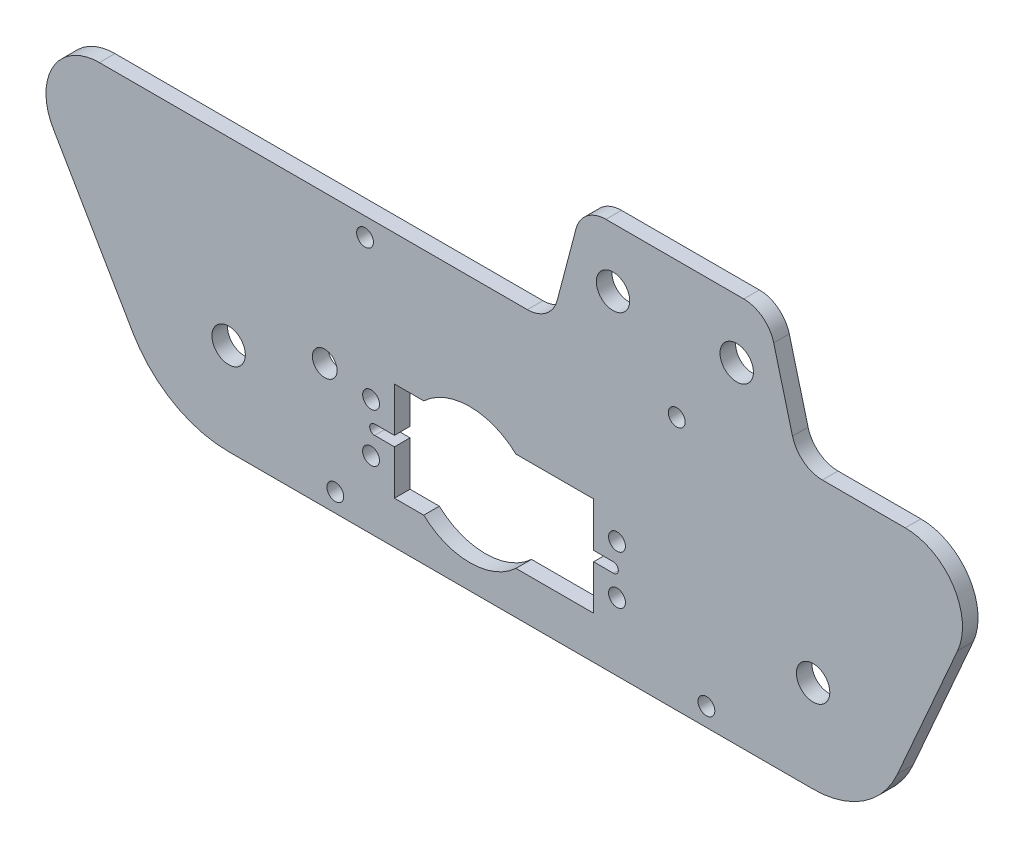
from build123d import *

# Parameters (mm, degrees)
SKETCH1_R           = 3.429
SKETCH1_R_2         = 2.54
BOSS_EXTRUDE1_DEPTH = 3.2004
SKETCH2_R           = 1.7272
CUT_EXTRUDE1_DEPTH  = 3.2004
SKETCH5_R           = 1.7272
SKETCH5_W           = 40.894
SKETCH5_H           = 20.32
CUT_EXTRUDE3_DEPTH  = 4.2004
CUT_EXTRUDE4_DEPTH  = 3.2004
SKETCH9_R           = 13.885201093
CUT_EXTRUDE7_DEPTH  = 3.2004
SKETCH10_R          = 3.429
BOSS_EXTRUDE2_DEPTH = 3.2004
FILLET1_R           = 6.35


with BuildPart() as part:
    # Sketch1 → Boss-Extrude1 (new body)
    with BuildSketch(Plane.XY):
        with BuildLine():
            Line((0, 0), (120.015, 0))
            ThreePointArc((120.015, 0), (130.351788397, 3.075697789), (137.325636158, 11.302152593))
            Line((137.325636158, 11.302152593), (149.69326877, 39.451329485))
            ThreePointArc((149.69326877, 39.451329485), (148.774539583, 50.600046625), (138.937102863, 55.925719911))
            Line((138.937102863, 55.925719911), (-26.54325766, 55.925719911))
            ThreePointArc((-26.54325766, 55.925719911), (-36.046025914, 50.429200208), (-36.019801229, 39.451329485))
            Line((-36.019801229, 39.451329485), (-19.648099871, 11.302152593))
            ThreePointArc((-19.648099871, 11.302152593), (-11.333429333, 3.027112684), (0, 0))
        make_face()
        with Locations((120.015, 18.90776)):
            Circle(SKETCH1_R, mode=Mode.SUBTRACT)
        with Locations((0, 18.90776)):
            Circle(SKETCH1_R, mode=Mode.SUBTRACT)
        with Locations((19.734727626, 25.566426992)):
            Circle(SKETCH1_R_2, mode=Mode.SUBTRACT)
    extrude(amount=BOSS_EXTRUDE1_DEPTH)

    # Sketch2 → Cut-Extrude1 (cut)
    with BuildSketch(Plane(origin=(0, 0, 0), x_dir=(-1, 0, 0), z_dir=(0, 0, -1))):
        with Locations((-92.0115, 52.115719911)):
            Circle(SKETCH2_R)
        with Locations((-28.0035, 52.115719911)):
            Circle(SKETCH2_R)
        with Locations((-98.1075, 3.81)):
            Circle(SKETCH2_R)
        with Locations((-21.9075, 3.81)):
            Circle(SKETCH2_R)
    extrude(amount=-CUT_EXTRUDE1_DEPTH, mode=Mode.SUBTRACT)

    # Sketch5 → Cut-Extrude3 (cut, through all)
    with BuildSketch(Plane(origin=(0, 0, 0), x_dir=(-1, 0, 0), z_dir=(0, 0, -1))):
        with Locations((-79.746999972, 23.90776)):
            Circle(SKETCH5_R)
        with Locations((-29.246999972, 13.90776)):
            Circle(SKETCH5_R)
        with Locations((-29.246999972, 23.90776)):
            Circle(SKETCH5_R)
        with Locations((-79.746999972, 13.90776)):
            Circle(SKETCH5_R)
        with Locations((-54.496999972, 18.90776)):
            Rectangle(SKETCH5_W, SKETCH5_H)
    extrude(amount=-CUT_EXTRUDE3_DEPTH, mode=Mode.SUBTRACT)

    # Sketch6 → Cut-Extrude4 (cut)
    with BuildSketch(Plane.XY.offset(3.2004)):
        with BuildLine():
            Line((29.985999972, 19.92376), (34.049999972, 19.92376))
            Line((34.049999972, 19.92376), (34.049999972, 17.89176))
            Line((34.049999972, 17.89176), (29.985999972, 17.89176))
            ThreePointArc((29.985999972, 17.89176), (28.969999972, 18.90776), (29.985999972, 19.92376))
        make_face()
        with BuildLine():
            Line((74.943999972, 19.92376), (79.007999972, 19.92376))
            ThreePointArc((79.007999972, 19.92376), (80.023999972, 18.90776), (79.007999972, 17.89176))
            Line((79.007999972, 17.89176), (74.943999972, 17.89176))
            Line((74.943999972, 17.89176), (74.943999972, 19.92376))
        make_face()
    extrude(amount=-CUT_EXTRUDE4_DEPTH, mode=Mode.SUBTRACT)

    # Sketch9 → Cut-Extrude7 (cut)
    with BuildSketch(Plane(origin=(0, 0, 0), x_dir=(-1, 0, 0), z_dir=(0, 0, -1))):
        with Locations((-49.53, 18.90776)):
            Circle(SKETCH9_R)
    extrude(amount=-CUT_EXTRUDE7_DEPTH, mode=Mode.SUBTRACT)

    # Sketch10 → Boss-Extrude2 (add)
    with BuildSketch(Plane.XY.offset(3.2004)):
        Polygon((72.5805, 80.055719911), (110.6805, 80.055719911), (117.0305, 55.925719911), (66.2305, 55.925719911), align=None)
        with Locations((78.9305, 67.990719911)):
            Circle(SKETCH10_R, mode=Mode.SUBTRACT)
        with Locations((104.3305, 67.990719911)):
            Circle(SKETCH10_R, mode=Mode.SUBTRACT)
    extrude(amount=-BOSS_EXTRUDE2_DEPTH)

    # Fillet1
    fillet1_edges = [part.edges().sort_by_distance(p)[0] for p in [
        (117.0305, 55.925719911, 1.6002),
        (110.6805, 80.055719911, 1.6002),
        (72.5805, 80.055719911, 1.6002),
        (66.2305, 55.925719911, 1.6002),
    ]]
    fillet(fillet1_edges, radius=FILLET1_R)


solid = part.part
